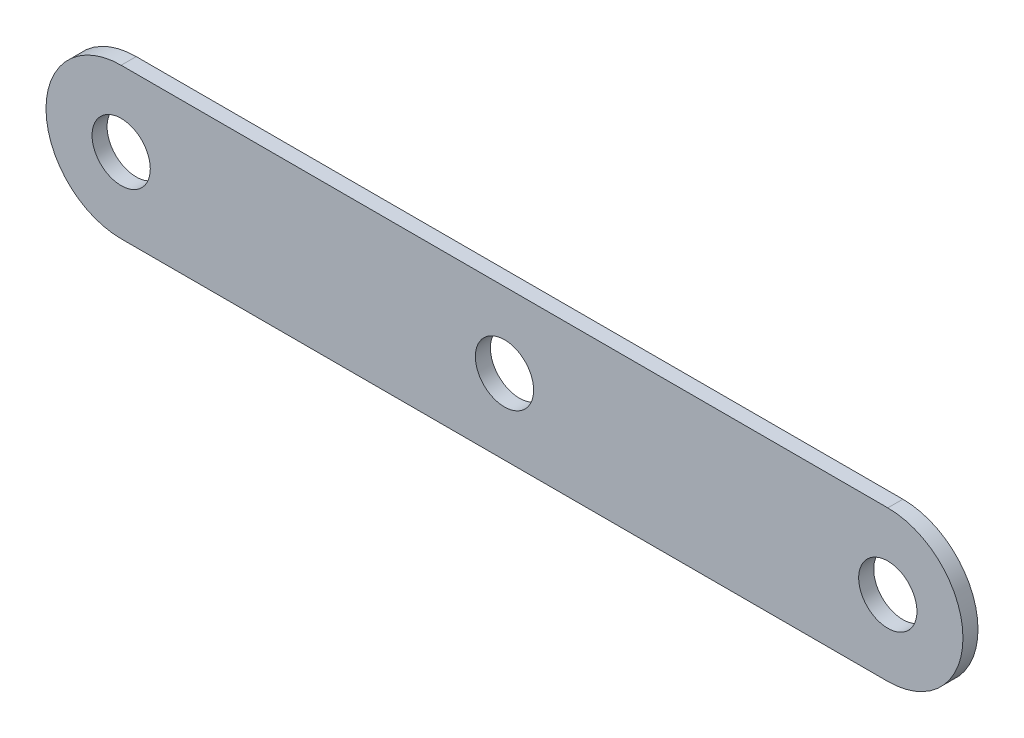
from build123d import *

# Parameters (mm, degrees)
BOSS_EXTRUDE1_DEPTH = 4
CUT_EXTRUDE1_REACH  = 6
SKETCH2_R           = 7.75
CUT_EXTRUDE2_REACH  = 6
SKETCH3_R           = 7.75


with BuildPart() as part:
    # Sketch1 → Boss-Extrude1 (new body)
    with BuildSketch(Plane.XY):
        with BuildLine():
            Line((0, 20), (204, 20))
            ThreePointArc((204, 20), (224, 0), (204, -20))
            Line((204, -20), (0, -20))
            ThreePointArc((0, -20), (-20, 0), (0, 20))
        make_face()
    extrude(amount=BOSS_EXTRUDE1_DEPTH)

    # Sketch2 → Cut-Extrude1 (cut, up to next)
    with BuildSketch(Plane.XY.offset(4), mode=Mode.PRIVATE) as cut_extrude1_sk1:
        Circle(SKETCH2_R)
    cut_extrude1_tool1 = extrude(cut_extrude1_sk1.sketch, amount=-CUT_EXTRUDE1_REACH, mode=Mode.PRIVATE) & part.part
    add(cut_extrude1_tool1.solids().sort_by_distance((0, 0, 4))[0], mode=Mode.SUBTRACT)
    # Sketch2 → Cut-Extrude1 (cut, up to next)
    with BuildSketch(Plane.XY.offset(4), mode=Mode.PRIVATE) as cut_extrude1_sk2:
        with Locations((204, 0)):
            Circle(SKETCH2_R)
    cut_extrude1_tool2 = extrude(cut_extrude1_sk2.sketch, amount=-CUT_EXTRUDE1_REACH, mode=Mode.PRIVATE) & part.part
    add(cut_extrude1_tool2.solids().sort_by_distance((204, 0, 4))[0], mode=Mode.SUBTRACT)

    # Sketch3 → Cut-Extrude2 (cut, up to next)
    with BuildSketch(Plane.XY.offset(4), mode=Mode.PRIVATE) as cut_extrude2_sk1:
        with Locations((102, 0)):
            Circle(SKETCH3_R)
    cut_extrude2_tool1 = extrude(cut_extrude2_sk1.sketch, amount=-CUT_EXTRUDE2_REACH, mode=Mode.PRIVATE) & part.part
    add(cut_extrude2_tool1.solids().sort_by_distance((102, 0, 4))[0], mode=Mode.SUBTRACT)


solid = part.part
